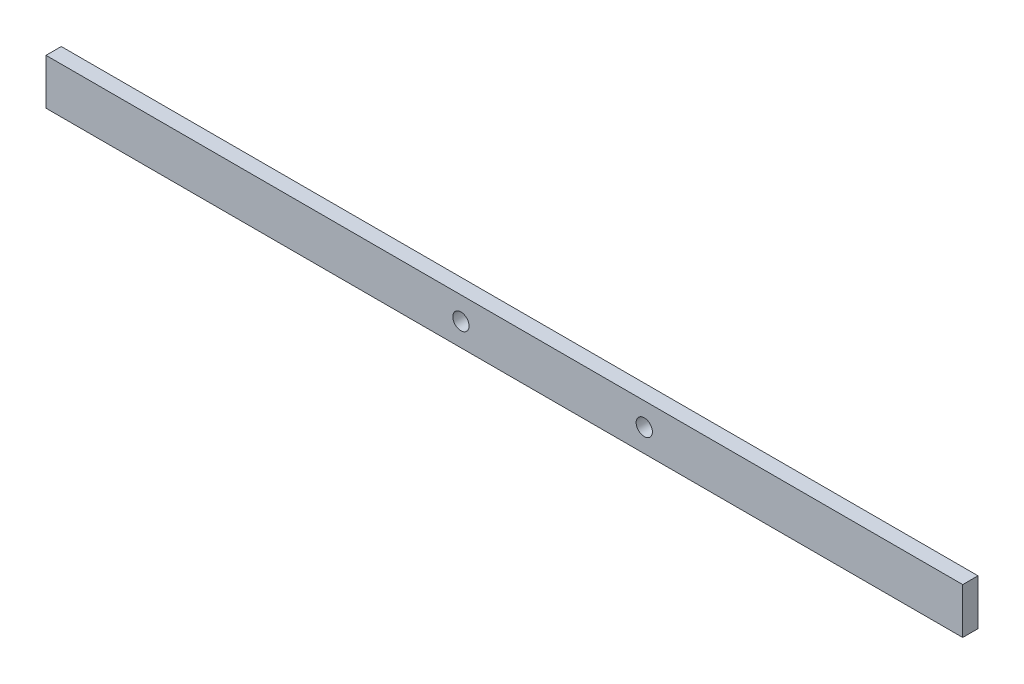
from build123d import *

# Parameters (mm, degrees)
SKETCH1_W               = 381
SKETCH1_H               = 19.05
BOSS_EXTRUDE1_DEPTH     = 6.35
F_1_4_CLEARANCE_HOLE1_D = 6.7564


with BuildPart() as part:
    # Sketch1 → Boss-Extrude1 (new body)
    with BuildSketch(Plane.XY):
        Rectangle(SKETCH1_W, SKETCH1_H)
    extrude(amount=BOSS_EXTRUDE1_DEPTH)

    # 1/4 Clearance Hole1 (through all)
    with Locations(Plane.XY.offset(6.35)):
        with Locations((-18.0467, 0), (58.1533, 0)):
            Hole(F_1_4_CLEARANCE_HOLE1_D / 2)


solid = part.part
